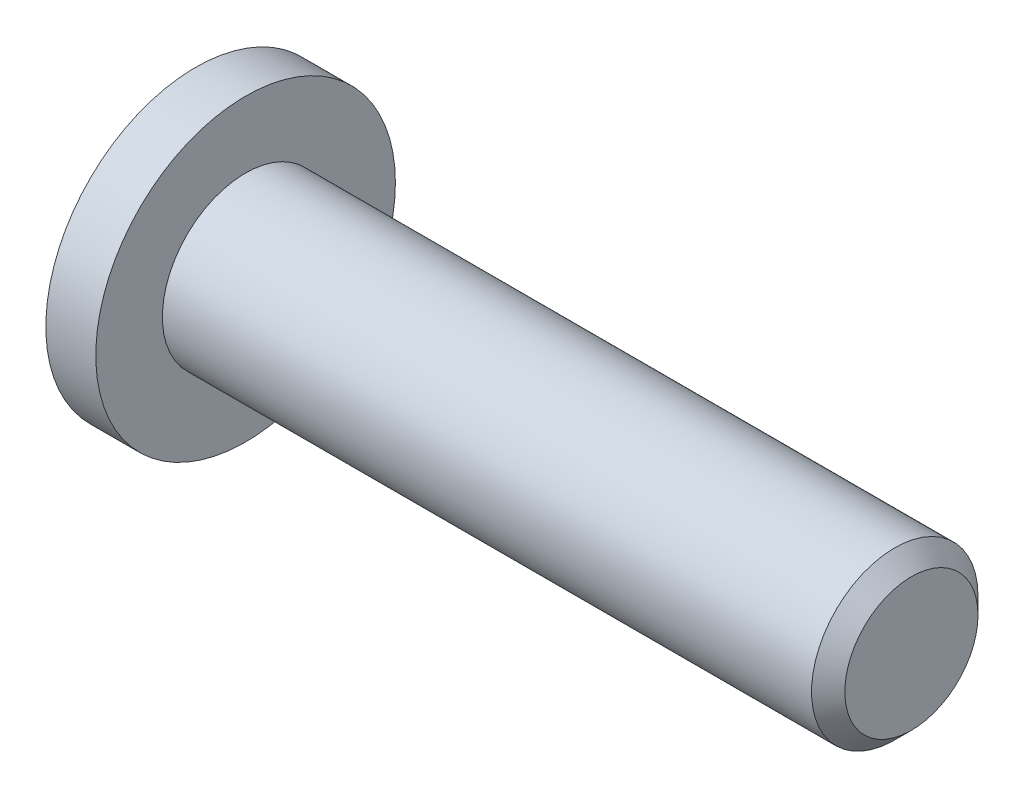
from build123d import *

# Parameters (mm, degrees)
SKETCH1_R     = 4.5
HEAD_DEPTH    = 1.5
SKETCH2_R     = 2.5
BODY_DEPTH    = 20
DRIVE_DEPTH   = 3
CHAMFER1_SIZE = 0.5


with BuildPart() as part:
    # Sketch1 → Head (new body)
    with BuildSketch(Plane(origin=(0, 0, 0), x_dir=(0, 0, -1), z_dir=(1, 0, 0))):
        Circle(SKETCH1_R)
    extrude(amount=HEAD_DEPTH)

    # Sketch2 → Body (add)
    with BuildSketch(Plane(origin=(1.5, 0, 0), x_dir=(0, 0, -1), z_dir=(1, 0, 0))):
        Circle(SKETCH2_R)
    extrude(amount=BODY_DEPTH)

    # Sketch3 → Drive (cut)
    with BuildSketch(Plane.ZY):
        Polygon((0, 1.732050808), (-1.5, 0.866025404), (-1.5, -0.866025404), (0, -1.732050808), (1.5, -0.866025404), (1.5, 0.866025404), align=None)
    extrude(amount=-DRIVE_DEPTH, mode=Mode.SUBTRACT)

    # Chamfer1
    chamfer1_edges = [part.edges().sort_by_distance(p)[0] for p in [
        (21.5, 0, 2.5),
    ]]
    chamfer(chamfer1_edges, length=CHAMFER1_SIZE)


solid = part.part
